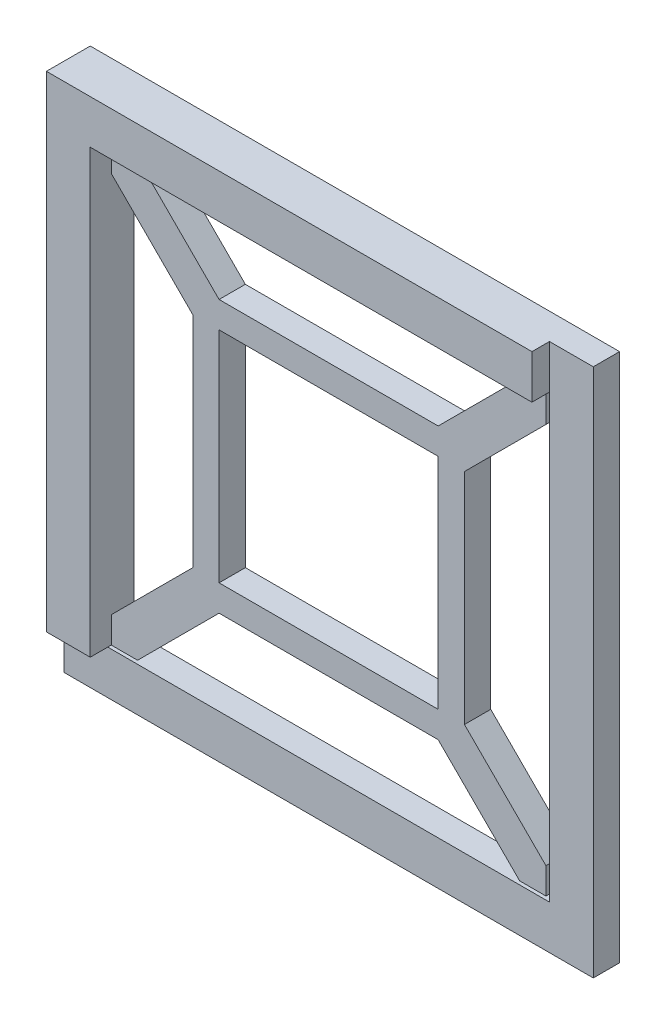
from build123d import *

# Parameters (mm, degrees)
SKETCH1_W             = 60.4
SKETCH1_H             = 60.4
SKETCH1_W_2           = 50.4
SKETCH1_H_2           = 50.4
EXTRUDE_THIN1_DEPTH   = 3
BOSS_EXTRUDE1_DEPTH   = 3
BOSS_EXTRUDE1_2_DEPTH = 3
BOSS_EXTRUDE1_3_DEPTH = 3
BOSS_EXTRUDE1_4_DEPTH = 3
SKETCH1_5_W           = 31
SKETCH1_5_H           = 31
SKETCH1_5_W_2         = 25
SKETCH1_5_H_2         = 25
EXTRUDE_THIN2_DEPTH   = 3
EXTRUDE_THIN3_DEPTH   = 2


with BuildPart() as part:
    # Sketch1 → Extrude-Thin1 (new body)
    with BuildSketch(Plane.XY):
        Rectangle(SKETCH1_W, SKETCH1_H)
        Rectangle(SKETCH1_W_2, SKETCH1_H_2, mode=Mode.SUBTRACT)
    extrude(amount=EXTRUDE_THIN1_DEPTH)

    # Sketch2 → Extrude-Thin3 (add)
    with BuildSketch(Plane.XY.offset(3)):
        Polygon((-25.2, -25.2), (-25.2, 25.2), (25.2, 25.2), (25.2, 30.2), (-30.2, 30.2), (-30.2, -25.2), align=None)
    extrude(amount=EXTRUDE_THIN3_DEPTH)


with BuildPart() as body_2:
    # Sketch1_4 → Boss-Extrude1 (new body)
    with BuildSketch(Plane.XY):
        Polygon((-21.8, 24.8), (-24.8, 24.8), (-24.8, 21.8), (-12.5, 9.5), (-12.5, 12.5), (-9.5, 12.5), align=None)
    extrude(amount=BOSS_EXTRUDE1_DEPTH)



with BuildPart() as body_3:
    # Sketch1_4 → Boss-Extrude1 2 (new body)
    with BuildSketch(Plane.XY):
        Polygon((24.8, 24.8), (21.8, 24.8), (9.5, 12.5), (12.5, 12.5), (12.5, 9.5), (24.8, 21.8), align=None)
    extrude(amount=BOSS_EXTRUDE1_2_DEPTH)


with BuildPart() as body_4:
    # Sketch1_4 → Boss-Extrude1 3 (new body)
    with BuildSketch(Plane.XY):
        Polygon((-12.5, -9.5), (-24.8, -21.8), (-24.8, -24.8), (-21.8, -24.8), (-9.5, -12.5), (-12.5, -12.5), align=None)
    extrude(amount=BOSS_EXTRUDE1_3_DEPTH)


with BuildPart() as body_5:
    # Sketch1_4 → Boss-Extrude1 4 (new body)
    with BuildSketch(Plane.XY):
        Polygon((24.8, -24.8), (24.8, -21.8), (12.5, -9.5), (12.5, -12.5), (9.5, -12.5), (21.8, -24.8), align=None)
    extrude(amount=BOSS_EXTRUDE1_4_DEPTH)


with BuildPart() as body_2_1:
    add(body_2.part)

    add(body_3.part)  # Extrude-Thin2 merges body 3

    add(body_4.part)  # Extrude-Thin2 merges body 4

    add(body_5.part)  # Extrude-Thin2 merges body 5
    # Sketch1_5 → Extrude-Thin2 (add)
    with BuildSketch(Plane.XY):
        Rectangle(SKETCH1_5_W, SKETCH1_5_H)
        Rectangle(SKETCH1_5_W_2, SKETCH1_5_H_2, mode=Mode.SUBTRACT)
    extrude(amount=EXTRUDE_THIN2_DEPTH)


solid = Compound([part.part, body_2_1.part])
